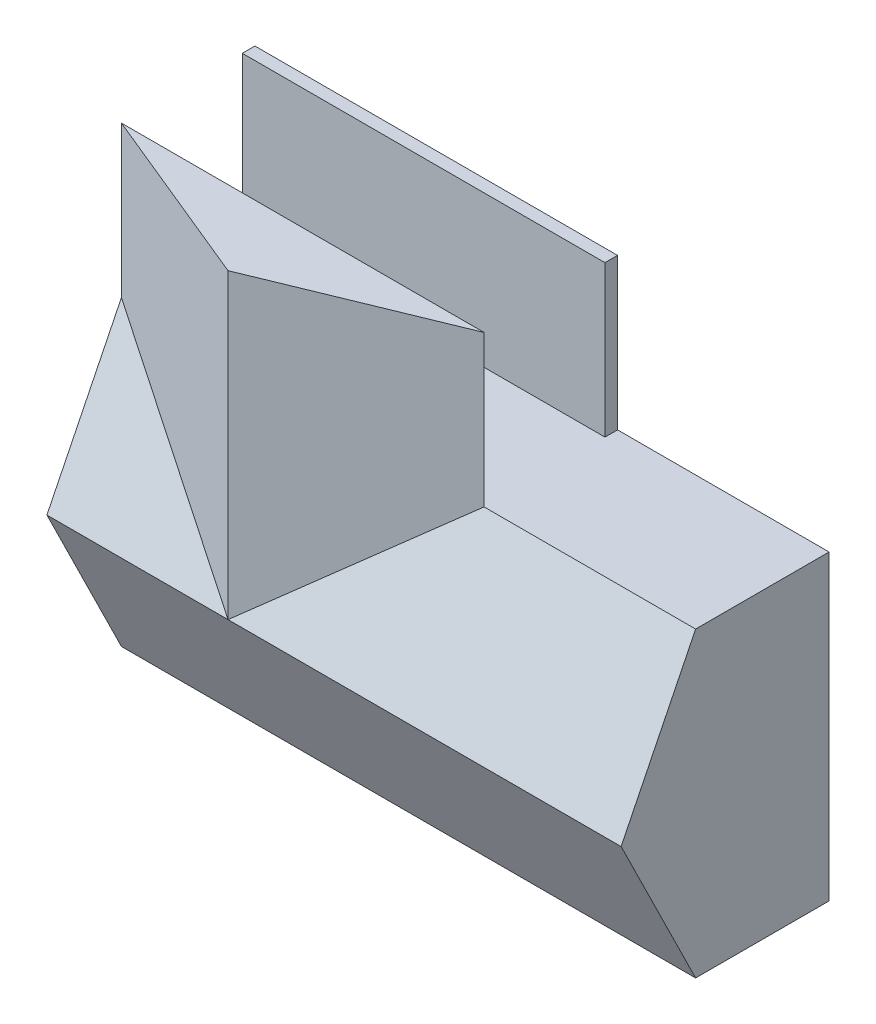
from build123d import *

# Parameters (mm, degrees)
SKETCH3_W           = 11582.4
SKETCH3_H           = 6096
SKETCH3_W_2         = 4341.154286856
SKETCH3_H_2         = 914.4
SKETCH3_W_3         = 1676.4
SKETCH3_H_3         = 2330.801356814
SKETCH3_W_4         = 2663.595025017
SKETCH3_H_4         = 2342.798643186
SKETCH3_W_5         = 1043.645713144
SKETCH3_W_6         = 4013.2
SKETCH3_W_7         = 3708.4
BOSS_EXTRUDE1_DEPTH = 2438.4
SKETCH4_W           = 11582.4
SKETCH4_H           = 6096
BOSS_EXTRUDE2_DEPTH = 254
SKETCH5_W           = 3178.404974983
SKETCH5_H           = 101.6
BOSS_EXTRUDE3_DEPTH = 1016
BOSS_EXTRUDE4_DEPTH = 11582.4
SKETCH8_W           = 7315.2
SKETCH8_H           = 3048
BOSS_EXTRUDE6_DEPTH = 254
BOSS_EXTRUDE9_REACH = 9146


with BuildPart() as part:
    # Sketch3 → Boss-Extrude1 (new body)
    with BuildSketch(Plane.XY):
        with Locations((5791.2, 3048)):
            Rectangle(SKETCH3_W, SKETCH3_H)
        Polygon((152.4, 152.4), (4550.004974983, 152.4), (4550.004974983, 2596.798643186), (5842, 2596.798643186), (5842, 3511.198643186), (5842, 5943.6), (152.4, 5943.6), align=None, mode=Mode.SUBTRACT)
        with Locations((8114.177143428, 3053.998643186)):
            Rectangle(SKETCH3_W_2, SKETCH3_H_2, mode=Mode.SUBTRACT)
        with Locations((6781.8, 4778.199321593)):
            Rectangle(SKETCH3_W_3, SKETCH3_H_3, mode=Mode.SUBTRACT)
        with Locations((5983.402487492, 1323.799321593)):
            Rectangle(SKETCH3_W_4, SKETCH3_H_4, mode=Mode.SUBTRACT)
        with Locations((10908.177143428, 3053.998643186)):
            Rectangle(SKETCH3_W_5, SKETCH3_H_2, mode=Mode.SUBTRACT)
        with Locations((9423.4, 1323.799321593)):
            Rectangle(SKETCH3_W_6, SKETCH3_H_4, mode=Mode.SUBTRACT)
        with Locations((9575.8, 4778.199321593)):
            Rectangle(SKETCH3_W_7, SKETCH3_H_3, mode=Mode.SUBTRACT)
    extrude(amount=BOSS_EXTRUDE1_DEPTH)

    # Sketch4 → Boss-Extrude2 (add)
    with BuildSketch(Plane(origin=(0, 0, 0), x_dir=(-1, 0, 0), z_dir=(0, 0, -1))):
        with Locations((-5791.2, 3048)):
            Rectangle(SKETCH4_W, SKETCH4_H)
    extrude(amount=BOSS_EXTRUDE2_DEPTH)

    # Sketch5 → Boss-Extrude3 (add)
    with BuildSketch(Plane.XY):
        with Locations((1741.602487492, 2545.998643186)):
            Rectangle(SKETCH5_W, SKETCH5_H)
    extrude(amount=BOSS_EXTRUDE3_DEPTH)

    # Sketch6 → Boss-Extrude4 (add)
    with BuildSketch(Plane.ZY):
        Polygon((2438.4, 6096), (2438.4, 0), (3941.507258543, 3048), align=None)
    extrude(amount=-BOSS_EXTRUDE4_DEPTH)

    # Boss-Extrude9: up to this face of the body (flat: up to its plane)
    boss_extrude9_end = Plane(part.part.faces().sort_by_distance((5791.2, 4572, 3189.953629272))[0])
    # Sketch10 → Boss-Extrude9 (add, up to the picked face)
    with BuildSketch(Plane(origin=(0, 9144, 0), x_dir=(1, 0, 0), z_dir=(0, 1, 0)), mode=Mode.PRIVATE) as boss_extrude9_sk1:
        Polygon((7315.2, -2438.4), (0, -2438.4), (3653.246788264, -3941.507258543), align=None)
    boss_extrude9_tool1 = split(extrude(boss_extrude9_sk1.sketch, amount=-BOSS_EXTRUDE9_REACH, mode=Mode.PRIVATE), bisect_by=boss_extrude9_end, keep=Keep.BOTH, mode=Mode.PRIVATE)
    add(boss_extrude9_tool1.solids().sort_by_distance((3656.148929, 9144, 2939.435753))[0])


with BuildPart() as body_2:
    # Sketch8 → Boss-Extrude6 (new body)
    with BuildSketch(Plane(origin=(0, 0, -254), x_dir=(-1, 0, 0), z_dir=(0, 0, -1))):
        with Locations((-3657.6, 7620)):
            Rectangle(SKETCH8_W, SKETCH8_H)
    extrude(amount=-BOSS_EXTRUDE6_DEPTH)


solid = Compound([part.part, body_2.part])
